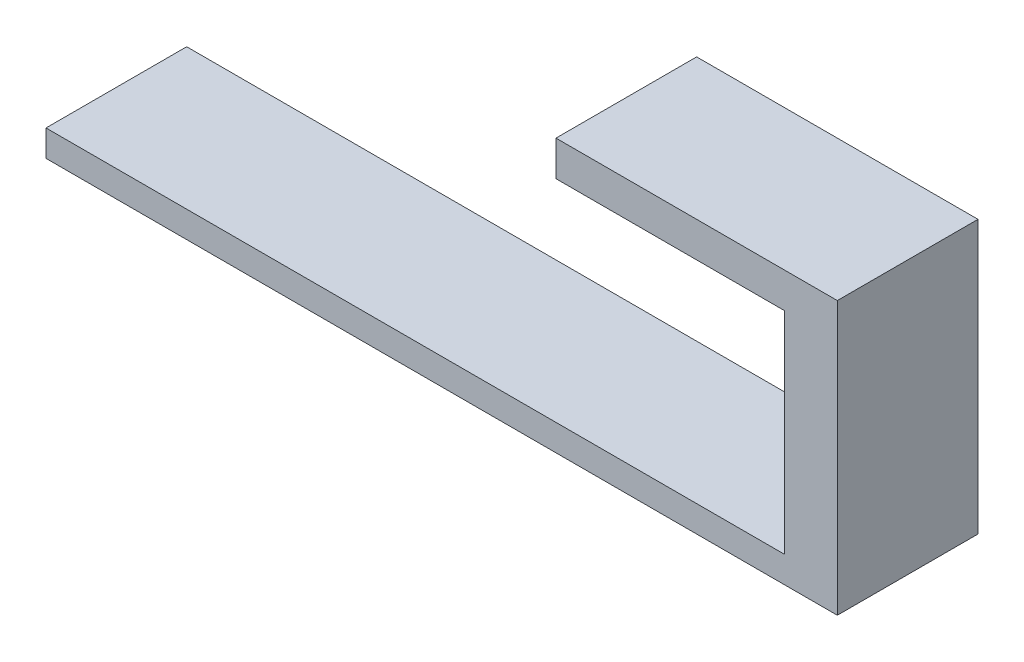
from build123d import *

# Parameters (mm, degrees)
SKETCH1_W           = 45
SKETCH1_H           = 8
BOSS_EXTRUDE1_DEPTH = 1.5
SKETCH2_W           = 3
SKETCH2_H           = 8
BOSS_EXTRUDE2_DEPTH = 14
SKETCH3_W           = 8
SKETCH3_H           = 2
BOSS_EXTRUDE3_DEPTH = 13


with BuildPart() as part:
    # Sketch1 → Boss-Extrude1 (new body)
    with BuildSketch(Plane(origin=(0, 0, 0), x_dir=(1, 0, 0), z_dir=(0, 1, 0))):
        Rectangle(SKETCH1_W, SKETCH1_H)
    extrude(amount=BOSS_EXTRUDE1_DEPTH)

    # Sketch2 → Boss-Extrude2 (add)
    with BuildSketch(Plane(origin=(0, 1.5, 0), x_dir=(1, 0, 0), z_dir=(0, 1, 0))):
        with Locations((21, 0)):
            Rectangle(SKETCH2_W, SKETCH2_H)
    extrude(amount=BOSS_EXTRUDE2_DEPTH)

    # Sketch3 → Boss-Extrude3 (add)
    with BuildSketch(Plane.ZY.offset(-19.5)):
        with Locations((0, 14.5)):
            Rectangle(SKETCH3_W, SKETCH3_H)
    extrude(amount=BOSS_EXTRUDE3_DEPTH)


solid = part.part
